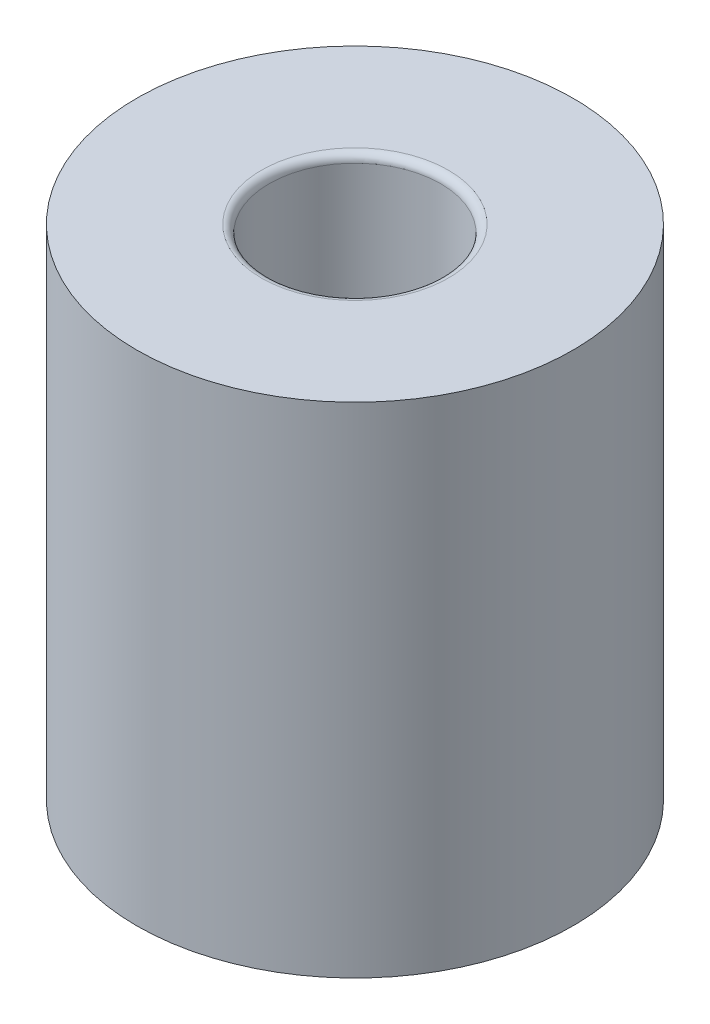
from build123d import *

# Parameters (mm, degrees)
SKETCH1_R           = 3.5
BOSS_EXTRUDE1_DEPTH = 8
SKETCH2_R           = 1.375
CUT_EXTRUDE1_DEPTH  = 8
FILLET1_R           = 0.125


with BuildPart() as part:
    # Sketch1 → Boss-Extrude1 (new body)
    with BuildSketch(Plane(origin=(0, 0, 0), x_dir=(1, 0, 0), z_dir=(0, 1, 0))):
        Circle(SKETCH1_R)
    extrude(amount=BOSS_EXTRUDE1_DEPTH)

    # Sketch2 → Cut-Extrude1 (cut)
    with BuildSketch(Plane(origin=(0, 8, 0), x_dir=(1, 0, 0), z_dir=(0, 1, 0))):
        Circle(SKETCH2_R)
    extrude(amount=-CUT_EXTRUDE1_DEPTH, mode=Mode.SUBTRACT)

    # Fillet1
    fillet1_edges = [part.edges().sort_by_distance(p)[0] for p in [
        (-1.375, 0, 0),
        (-1.375, 8, 0),
    ]]
    fillet(fillet1_edges, radius=FILLET1_R)


solid = part.part
